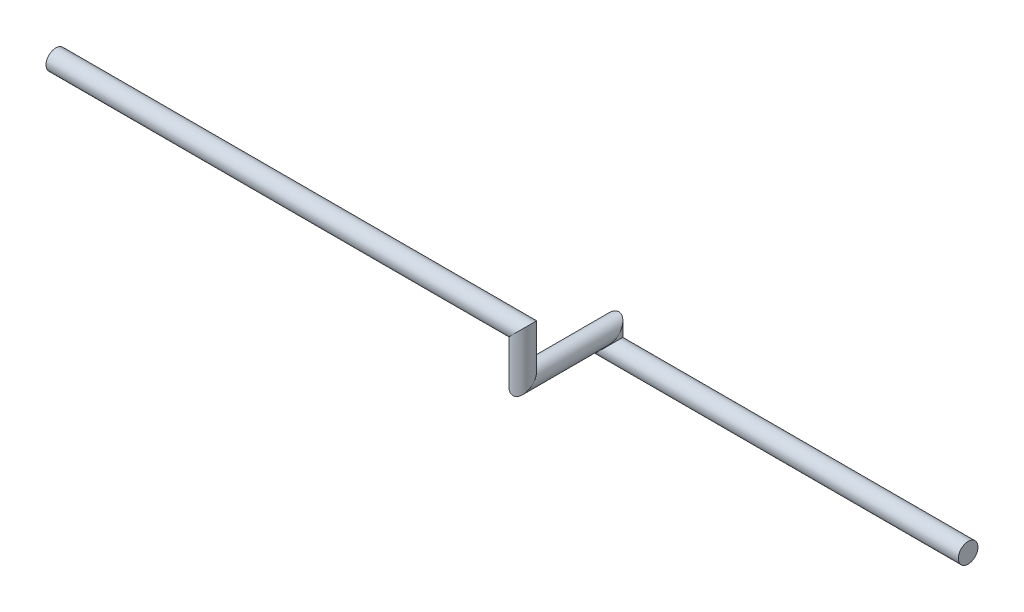
from build123d import *

# Parameters (mm, degrees)
CROQUIS1_R = 13.7


with BuildPart() as part:
    # Barrer1: sweep along a curve in space
    with BuildLine() as barrer1_path:
        Line((0, 0, 0), (-500, 0, 0))
        Line((-500, 0, 0), (-500, 20, 0))
        Line((-500, 20, 0), (-500, 20, 120))
        Line((-500, 20, 120), (-500, 80, 120))
        Line((-500, 80, 120), (-1150, 80, 120))
    # Croquis1 → Barrer1 (sweep)
    with BuildSketch(Plane(origin=(0, 0, 0), x_dir=(0, 0, -1), z_dir=(1, 0, 0))):
        Circle(CROQUIS1_R)
    sweep(path=barrer1_path.line, transition=Transition.RIGHT)


solid = part.part
